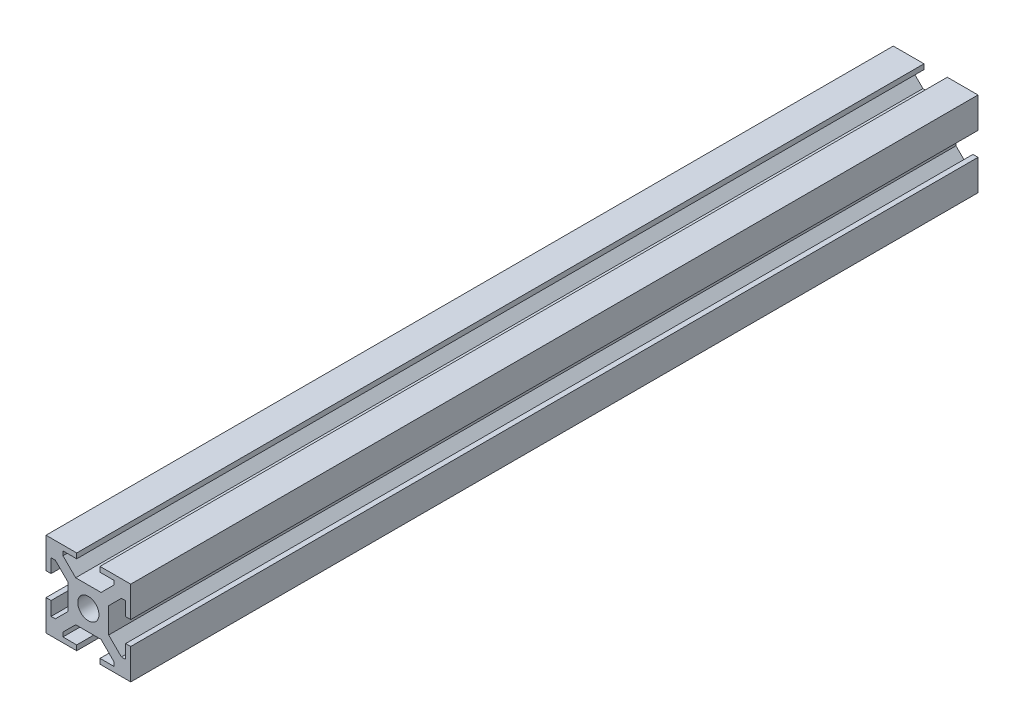
from build123d import *

# Parameters (mm, degrees)
ESQUISSE1_W             = 20
ESQUISSE1_H             = 20
BOSS_EXTRU_1_DEPTH      = 200
ESQUISSE2_W             = 1.2
ESQUISSE2_H             = 5.5
ESQUISSE2_W_2           = 5.5
ESQUISSE2_H_2           = 1.2
ENL_V_MAT_EXTRU_1_DEPTH = 201
ENL_V_MAT_EXTRU_2_DEPTH = 201
ESQUISSE4_R             = 2.5
ENL_V_MAT_EXTRU_3_DEPTH = 201


with BuildPart() as part:
    # Esquisse1 → Boss.-Extru.1 (new body)
    with BuildSketch(Plane.XY):
        with Locations((-12.505109137, -9.909560068)):
            Rectangle(ESQUISSE1_W, ESQUISSE1_H)
    extrude(amount=BOSS_EXTRU_1_DEPTH)

    # Esquisse2 → Enlèv. mat.-Extru.1 (cut, through all)
    with BuildSketch(Plane.XY.offset(200)):
        with Locations((-21.905109137, -9.909560068)):
            Rectangle(ESQUISSE2_W, ESQUISSE2_H)
        with Locations((-12.505109137, -0.509560068)):
            Rectangle(ESQUISSE2_W_2, ESQUISSE2_H_2)
        with Locations((-3.105109137, -9.909560068)):
            Rectangle(ESQUISSE2_W, ESQUISSE2_H)
        with Locations((-12.505109137, -19.309560068)):
            Rectangle(ESQUISSE2_W_2, ESQUISSE2_H_2)
    extrude(amount=-ENL_V_MAT_EXTRU_1_DEPTH, mode=Mode.SUBTRACT)

    # Esquisse3 → Enlèv. mat.-Extru.2 (cut, through all)
    with BuildSketch(Plane.XY.offset(200)):
        Polygon((-21.305109137, -15.909560068), (-20.305109137, -15.909560068), (-17.305109137, -12.909560068), (-17.305109137, -6.909560068), (-20.305109137, -3.909560068), (-21.305109137, -3.909560068), align=None)
        Polygon((-18.505109137, -1.109560068), (-6.505109137, -1.109560068), (-6.505109137, -2.109560068), (-9.505109137, -5.109560068), (-15.505109137, -5.109560068), (-18.505109137, -2.109560068), align=None)
        Polygon((-3.705109137, -3.909560068), (-4.705109137, -3.909560068), (-7.705109137, -6.909560068), (-7.705109137, -12.909560068), (-4.705109137, -15.909560068), (-3.705109137, -15.909560068), align=None)
        Polygon((-6.505109137, -18.709560068), (-18.505109137, -18.709560068), (-18.505109137, -17.709560068), (-15.505109137, -14.709560068), (-9.505109137, -14.709560068), (-6.505109137, -17.709560068), align=None)
    extrude(amount=-ENL_V_MAT_EXTRU_2_DEPTH, mode=Mode.SUBTRACT)

    # Esquisse4 → Enlèv. mat.-Extru.3 (cut, through all)
    with BuildSketch(Plane.XY.offset(200)):
        with Locations((-12.505109137, -9.909560068)):
            Circle(ESQUISSE4_R)
    extrude(amount=-ENL_V_MAT_EXTRU_3_DEPTH, mode=Mode.SUBTRACT)


solid = part.part
